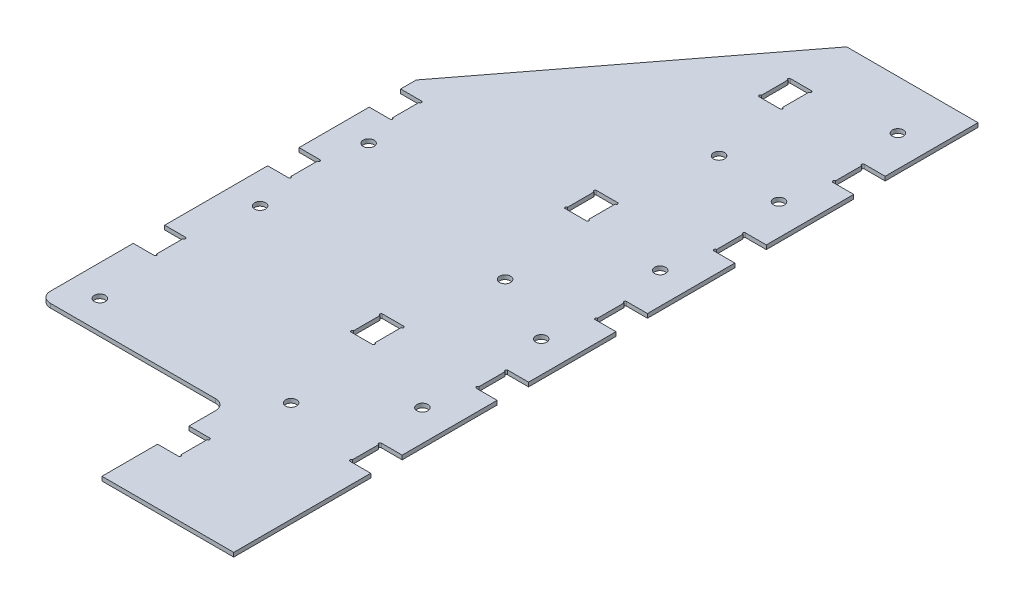
from build123d import *

# Parameters (mm, degrees)
BOSS_EXTRUDE1_DEPTH     = 2.54
FILLET1_R               = 6.35
SKETCH2_W               = 12.954
SKETCH2_H               = 19.304
SKETCH2_W_2             = 12.7
SKETCH2_H_2             = 19.05
CUT_EXTRUDE1_DEPTH      = 498.15765659
F_1_4_CLEARANCE_HOLE1_D = 6.7564
SKETCH5_R               = 0.79375
CUT_EXTRUDE2_DEPTH      = 498.15765659


with BuildPart() as part:
    # Sketch1 → Boss-Extrude1 (new body)
    with BuildSketch(Plane(origin=(0, 0, 0), x_dir=(1, 0, 0), z_dir=(0, 1, 0))):
        Polygon((0, 0), (-80.9625, 0), (-80.9625, 76.2), (-195.2625, 76.2), (-195.2625, 307.35814247), (-80.645, 457.2), (0, 457.2), align=None)
    extrude(amount=BOSS_EXTRUDE1_DEPTH)

    # Fillet1
    fillet1_edges = [part.edges().sort_by_distance(p)[0] for p in [
        (-80.9625, 1.27, -76.2),
        (-195.2625, 1.27, -76.2),
    ]]
    fillet(fillet1_edges, radius=FILLET1_R)

    # Sketch2 → Cut-Extrude1 (cut, through all)
    with BuildSketch(Plane(origin=(0, 2.54, 0), x_dir=(1, 0, 0), z_dir=(0, 1, 0))):
        with Locations((-74.6125, 413.385)):
            Rectangle(SKETCH2_W, SKETCH2_H)
        with Locations((-74.6125, 413.385)):
            Rectangle(SKETCH2_W_2, SKETCH2_H_2, mode=Mode.SUBTRACT)
        with Locations((-188.9125, 288.139828218)):
            Rectangle(SKETCH2_W, SKETCH2_H)
        with Locations((-188.9125, 288.139828218)):
            Rectangle(SKETCH2_W_2, SKETCH2_H_2, mode=Mode.SUBTRACT)
        with Locations((-74.6125, 294.3225)):
            Rectangle(SKETCH2_W, SKETCH2_H)
        with Locations((-74.6125, 294.3225)):
            Rectangle(SKETCH2_W_2, SKETCH2_H_2, mode=Mode.SUBTRACT)
        with Locations((-188.9125, 225.7425)):
            Rectangle(SKETCH2_W, SKETCH2_H)
        with Locations((-188.9125, 225.7425)):
            Rectangle(SKETCH2_W_2, SKETCH2_H_2, mode=Mode.SUBTRACT)
        with Locations((-188.9125, 143.1925)):
            Rectangle(SKETCH2_W, SKETCH2_H)
        with Locations((-188.9125, 143.1925)):
            Rectangle(SKETCH2_W_2, SKETCH2_H_2, mode=Mode.SUBTRACT)
        with Locations((-74.6125, 162.8775)):
            Rectangle(SKETCH2_W, SKETCH2_H)
        with Locations((-74.6125, 162.8775)):
            Rectangle(SKETCH2_W_2, SKETCH2_H_2, mode=Mode.SUBTRACT)
        with Locations((-74.6125, 43.815)):
            Rectangle(SKETCH2_W, SKETCH2_H)
        with Locations((-74.6125, 43.815)):
            Rectangle(SKETCH2_W_2, SKETCH2_H_2, mode=Mode.SUBTRACT)
        with Locations((-6.35, 93.82125)):
            Rectangle(SKETCH2_W, SKETCH2_H)
        with Locations((-6.35, 93.82125)):
            Rectangle(SKETCH2_W_2, SKETCH2_H_2, mode=Mode.SUBTRACT)
        with Locations((-6.35, 171.45)):
            Rectangle(SKETCH2_W, SKETCH2_H)
        with Locations((-6.35, 171.45)):
            Rectangle(SKETCH2_W_2, SKETCH2_H_2, mode=Mode.SUBTRACT)
        with Locations((-6.35, 244.475)):
            Rectangle(SKETCH2_W, SKETCH2_H)
        with Locations((-6.35, 244.475)):
            Rectangle(SKETCH2_W_2, SKETCH2_H_2, mode=Mode.SUBTRACT)
        with Locations((-6.35, 317.5)):
            Rectangle(SKETCH2_W, SKETCH2_H)
        with Locations((-6.35, 317.5)):
            Rectangle(SKETCH2_W_2, SKETCH2_H_2, mode=Mode.SUBTRACT)
        with Locations((-6.35, 390.525)):
            Rectangle(SKETCH2_W, SKETCH2_H)
        with Locations((-6.35, 390.525)):
            Rectangle(SKETCH2_W_2, SKETCH2_H_2, mode=Mode.SUBTRACT)
    extrude(amount=-CUT_EXTRUDE1_DEPTH, mode=Mode.SUBTRACT)


with BuildPart() as cut_extrude1_kept_piece:
    # of the separate pieces the step leaves, the one the design keeps (cut_extrude1_pieces_kept)
    add(part.part.solids().sort_by_distance((-80.9625, 0, -34.163))[0])

    # 1/4 Clearance Hole1 (through all)
    with Locations(Plane(origin=(0, 0, 0), x_dir=(-1, 0, 0), z_dir=(0, -1, 0))):
        with Locations((61.9125, 97.155), (19.05, 134.9375), (19.05, 207.9625), (61.9125, 228.6), (19.05, 280.9875), (19.05, 354.0125), (61.9125, 360.045), (19.05, 427.0375), (176.2125, 259.08), (176.2125, 192.405), (176.2125, 93.98)):
            Hole(F_1_4_CLEARANCE_HOLE1_D / 2)

    # Sketch5 → Cut-Extrude2 (cut, through all)
    with BuildSketch(Plane(origin=(0, 2.54, 0), x_dir=(1, 0, 0), z_dir=(0, 1, 0))):
        with Locations((-182.4355, 296.998078218)):
            Circle(SKETCH5_R)
        with Locations((-182.4355, 279.281578218)):
            Circle(SKETCH5_R)
        with Locations((-182.4355, 234.60075)):
            Circle(SKETCH5_R)
        with Locations((-182.4355, 216.88425)):
            Circle(SKETCH5_R)
        with Locations((-182.4355, 152.05075)):
            Circle(SKETCH5_R)
        with Locations((-182.4355, 134.33425)):
            Circle(SKETCH5_R)
        with Locations((-68.1355, 52.67325)):
            Circle(SKETCH5_R)
        with Locations((-68.1355, 34.95675)):
            Circle(SKETCH5_R)
        with Locations((-12.827, 84.963)):
            Circle(SKETCH5_R)
        with Locations((-12.827, 102.6795)):
            Circle(SKETCH5_R)
        with Locations((-68.1355, 171.73575)):
            Circle(SKETCH5_R)
        with Locations((-81.0895, 171.73575)):
            Circle(SKETCH5_R)
        with Locations((-81.0895, 154.01925)):
            Circle(SKETCH5_R)
        with Locations((-68.1355, 154.01925)):
            Circle(SKETCH5_R)
        with Locations((-12.827, 162.59175)):
            Circle(SKETCH5_R)
        with Locations((-12.827, 180.30825)):
            Circle(SKETCH5_R)
        with Locations((-12.827, 235.61675)):
            Circle(SKETCH5_R)
        with Locations((-12.827, 253.33325)):
            Circle(SKETCH5_R)
        with Locations((-68.1355, 285.46425)):
            Circle(SKETCH5_R)
        with Locations((-81.0895, 285.46425)):
            Circle(SKETCH5_R)
        with Locations((-81.0895, 303.18075)):
            Circle(SKETCH5_R)
        with Locations((-68.1355, 303.18075)):
            Circle(SKETCH5_R)
        with Locations((-12.827, 308.64175)):
            Circle(SKETCH5_R)
        with Locations((-12.827, 326.35825)):
            Circle(SKETCH5_R)
        with Locations((-12.827, 399.38325)):
            Circle(SKETCH5_R)
        with Locations((-12.827, 381.66675)):
            Circle(SKETCH5_R)
        with Locations((-68.1355, 422.24325)):
            Circle(SKETCH5_R)
        with Locations((-81.0895, 422.24325)):
            Circle(SKETCH5_R)
        with Locations((-81.0895, 404.52675)):
            Circle(SKETCH5_R)
        with Locations((-68.1355, 404.52675)):
            Circle(SKETCH5_R)
    extrude(amount=-CUT_EXTRUDE2_DEPTH, mode=Mode.SUBTRACT)


solid = cut_extrude1_kept_piece.part
